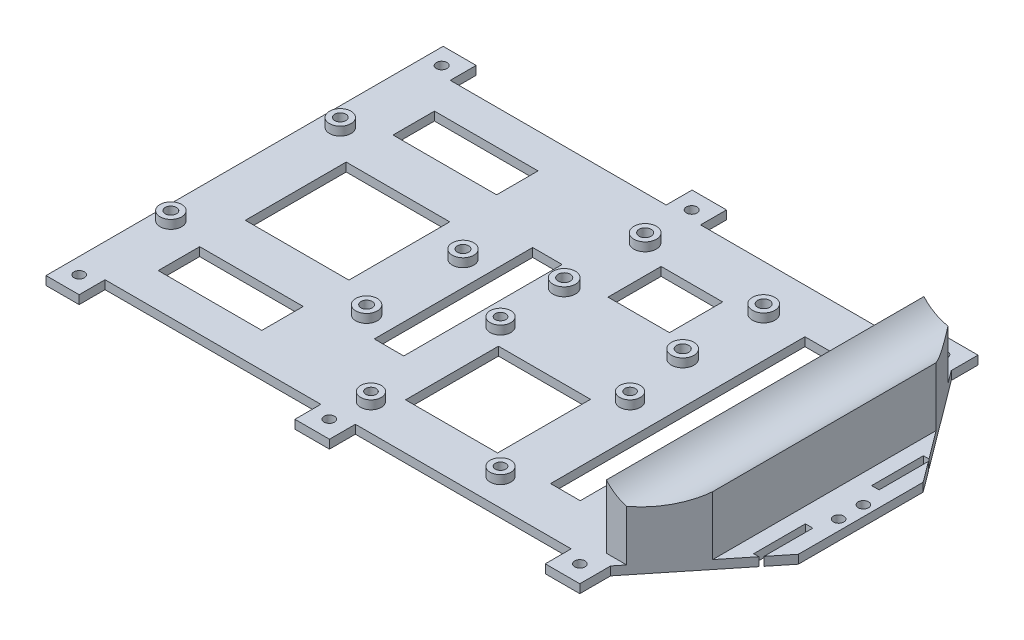
from build123d import *

# Parameters (mm, degrees)
BOSS_EXTRUDE1_DEPTH      = 2.5
SKETCH1_R                = 3.11925
SKETCH1_R_2              = 1.61925
BOSS_EXTRUDE2_DEPTH      = 2.5
SKETCH12_R               = 1.61925
CUT_EXTRUDE2_DEPTH       = 3.5
SKETCH15_R               = 3
BOSS_EXTRUDE6_DEPTH      = 2.5
SKETCH13_R               = 1.5
CUT_EXTRUDE5_DEPTH       = 3.5
CUT_EXTRUDE5_DEPTH_BACK  = 3.5
SKETCH16_R               = 3.25
SKETCH16_R_2             = 3.255054338
BOSS_EXTRUDE7_DEPTH      = 2.5
SKETCH17_R               = 1.75
SKETCH17_R_2             = 1.755054338
CUT_EXTRUDE6_DEPTH       = 1
CUT_EXTRUDE6_DEPTH_BACK  = 6
SKETCH24_R               = 1.534588162
SKETCH24_R_2             = 1.539679215
SKETCH24_R_3             = 1.53510928
SKETCH24_R_4             = 1.507254119
SKETCH24_R_5             = 1.501766116
SKETCH24_R_6             = 1.506723366
CUT_EXTRUDE7_DEPTH       = 3.5
CUT_EXTRUDE7_DEPTH_BACK  = 3.5
BOSS_EXTRUDE8_DEPTH      = 23
SKETCH28_W               = 1.910572049
SKETCH28_H               = 15
SKETCH28_W_2             = 2.161085764
CUT_EXTRUDE9_DEPTH       = 3.5
SKETCH30_W               = 30
SKETCH30_H               = 12
SKETCH30_W_2             = 8.543214141
SKETCH30_H_2             = 45.874985667
SKETCH30_H_3             = 29.216310988
SKETCH30_W_3             = 26.664834195
SKETCH30_H_4             = 26.922465443
SKETCH30_W_4             = 17.818641616
SKETCH30_H_5             = 15.402052611
SKETCH30_W_5             = 8.591934673
SKETCH30_H_6             = 73.671406809
CUT_EXTRUDE11_DEPTH      = 3.5
SKETCH29_R               = 12.3
CUT_EXTRUDE12_DEPTH      = 66.426944419
CUT_EXTRUDE12_DEPTH_BACK = 50.584496916
SKETCH31_R               = 1.5
CUT_EXTRUDE13_DEPTH      = 19.369261936
CUT_EXTRUDE13_DEPTH_BACK = 3.5
CUT_EXTRUDE14_DEPTH      = 12


with BuildPart() as part:
    # Sketch2 → Boss-Extrude1 (new body)
    with BuildSketch(Plane(origin=(0, -17.332299444, 0), x_dir=(-1, 0, 0), z_dir=(0, -1, 0))):
        Polygon((125.241603418, -58.531029956), (125.241603418, 41.468970044), (125.241603418, 48.975336237), (115.668802349, 48.975336237), (115.668802349, 41.468970044), (53.135946408, 41.468970044), (53.135946408, 48.975336237), (43.168799778, 48.975336237), (43.168799778, 41.468970044), (-19.254443916, 41.468970044), (-19.254443916, 48.975336237), (-29.674557938, 48.975336237), (-29.674557938, 41.234228149), (-53.610322333, 9.147791006), (-53.610322333, -26.975248892), (-29.352965282, -57.102703243), (-29.352965282, -66.036105098), (-19.352967368, -66.036105098), (-19.352967368, -58.531029956), (43.147035426, -58.531029956), (43.147035426, -66.036105098), (53.147035202, -66.036105098), (53.147035202, -58.531029956), (115.647037996, -58.531029956), (115.647037996, -66.036105098), (125.241603418, -66.036105098), align=None)
    extrude(amount=-BOSS_EXTRUDE1_DEPTH)

    # Sketch1 → Boss-Extrude2 (add)
    with BuildSketch(Plane(origin=(-134.962394185, -12.332299444, 36.871029956), x_dir=(1, 0, 0), z_dir=(0, 1, 0))):
        with Locations((14.01445, 2.71145)):
            Circle(SKETCH1_R)
        with Locations((14.01445, 2.71145)):
            Circle(SKETCH1_R_2, mode=Mode.SUBTRACT)
        with Locations((65.94475, 7.46125)):
            Circle(SKETCH1_R)
        with Locations((65.94475, 7.46125)):
            Circle(SKETCH1_R_2, mode=Mode.SUBTRACT)
        with Locations((65.94475, 35.38855)):
            Circle(SKETCH1_R)
        with Locations((65.94475, 35.38855)):
            Circle(SKETCH1_R_2, mode=Mode.SUBTRACT)
        with Locations((15.15745, 50.62855)):
            Circle(SKETCH1_R)
        with Locations((15.15745, 50.62855)):
            Circle(SKETCH1_R_2, mode=Mode.SUBTRACT)
    extrude(amount=-BOSS_EXTRUDE2_DEPTH)

    # Sketch12 → Cut-Extrude2 (cut, through all)
    with BuildSketch(Plane(origin=(0, -14.832299444, 0), x_dir=(1, 0, 0), z_dir=(0, 1, 0))):
        with Locations((-119.804944185, 13.757520044)):
            Circle(SKETCH12_R)
        with Locations((-69.017644185, -1.482479956)):
            Circle(SKETCH12_R)
        with Locations((-69.017644185, -29.409779956)):
            Circle(SKETCH12_R)
        with Locations((-120.947944185, -34.159579956)):
            Circle(SKETCH12_R)
    extrude(amount=-CUT_EXTRUDE2_DEPTH, mode=Mode.SUBTRACT)

    # Sketch15 → Boss-Extrude6 (add)
    with BuildSketch(Plane(origin=(0, -14.832299444, 0), x_dir=(1, 0, 0), z_dir=(0, 1, 0))):
        with Locations((-46.620694306, -50.539968272)):
            Circle(SKETCH15_R)
        with Locations((-46.620694306, -13.022091641)):
            Circle(SKETCH15_R)
        with Locations((-9.102817675, -50.539968272)):
            Circle(SKETCH15_R)
        with Locations((-9.102817675, -13.022091641)):
            Circle(SKETCH15_R)
    extrude(amount=BOSS_EXTRUDE6_DEPTH)

    # Sketch13 → Cut-Extrude5 (cut, two sides)
    with BuildSketch(Plane(origin=(0, -14.832299444, 0), x_dir=(1, 0, 0), z_dir=(0, 1, 0))) as cut_extrude5_sk:
        with Locations((-46.620694306, -13.022091641)):
            Circle(SKETCH13_R)
        with Locations((-9.102817675, -13.022091641)):
            Circle(SKETCH13_R)
        with Locations((-46.620694306, -50.539968272)):
            Circle(SKETCH13_R)
        with Locations((-9.102817675, -50.539968272)):
            Circle(SKETCH13_R)
    extrude(amount=CUT_EXTRUDE5_DEPTH, mode=Mode.SUBTRACT)
    extrude(cut_extrude5_sk.sketch, amount=-CUT_EXTRUDE5_DEPTH_BACK, mode=Mode.SUBTRACT)

    # Sketch16 → Boss-Extrude7 (add)
    with BuildSketch(Plane(origin=(0, -14.832299444, 0), x_dir=(1, 0, 0), z_dir=(0, 1, 0))):
        with Locations((-11.732899179, 28.299312351)):
            Circle(SKETCH16_R)
        with Locations((-12.172959949, 5.303522595)):
            Circle(SKETCH16_R_2)
        with Locations((-47.166553056, 5.973180288)):
            Circle(SKETCH16_R_2)
        with Locations((-46.726492287, 28.968970044)):
            Circle(SKETCH16_R)
    extrude(amount=BOSS_EXTRUDE7_DEPTH)

    # Sketch17 → Cut-Extrude6 (cut, two sides)
    with BuildSketch(Plane(origin=(0, -12.332299444, 0), x_dir=(1, 0, 0), z_dir=(0, 1, 0))) as cut_extrude6_sk:
        with Locations((-46.726492287, 28.968970044)):
            Circle(SKETCH17_R)
        with Locations((-47.166553056, 5.973180288)):
            Circle(SKETCH17_R_2)
        with Locations((-12.172959949, 5.303522595)):
            Circle(SKETCH17_R_2)
        with Locations((-11.732899179, 28.299312351)):
            Circle(SKETCH17_R)
    extrude(amount=CUT_EXTRUDE6_DEPTH, mode=Mode.SUBTRACT)
    extrude(cut_extrude6_sk.sketch, amount=-CUT_EXTRUDE6_DEPTH_BACK, mode=Mode.SUBTRACT)

    # Sketch24 → Cut-Extrude7 (cut, two sides)
    with BuildSketch(Plane(origin=(0, -14.832299444, 0), x_dir=(1, 0, 0), z_dir=(0, 1, 0))) as cut_extrude7_sk:
        with Locations((-120.631514326, 43.936289371)):
            Circle(SKETCH24_R)
        with Locations((-48.193182725, 43.936289371)):
            Circle(SKETCH24_R_2)
        with Locations((24.374871647, 43.936289371)):
            Circle(SKETCH24_R_3)
        with Locations((24.374871647, -61.035755979)):
            Circle(SKETCH24_R_4)
        with Locations((-48.193182725, -61.035755979)):
            Circle(SKETCH24_R_5)
        with Locations((-120.631514326, -61.035755979)):
            Circle(SKETCH24_R_6)
    extrude(amount=CUT_EXTRUDE7_DEPTH, mode=Mode.SUBTRACT)
    extrude(cut_extrude7_sk.sketch, amount=-CUT_EXTRUDE7_DEPTH_BACK, mode=Mode.SUBTRACT)

    # Sketch25 → Boss-Extrude8 (add)
    with BuildSketch(Plane(origin=(0, -14.832299444, 0), x_dir=(1, 0, 0), z_dir=(0, 1, 0))):
        Polygon((25.524416428, 37.468970044), (32.483356263, 37.468970044), (42.544257405, 23.982102995), (42.544257405, -40.719218001), (31.423568275, -54.531029956), (25.524416428, -54.531029956), align=None)
    extrude(amount=BOSS_EXTRUDE8_DEPTH)

    # Sketch28 → Cut-Extrude9 (cut, through all)
    with BuildSketch(Plane(origin=(0, -14.832299444, 0), x_dir=(1, 0, 0), z_dir=(0, 1, 0))):
        with Locations((21.640674678, -25.829400353)):
            Rectangle(SKETCH28_W, SKETCH28_H)
        with Locations((21.640674678, 8.33851306)):
            Rectangle(SKETCH28_W, SKETCH28_H)
        with Locations((48.076503584, -25.829400353)):
            Rectangle(SKETCH28_W_2, SKETCH28_H)
        with Locations((48.076503584, 8.33851306)):
            Rectangle(SKETCH28_W_2, SKETCH28_H)
    extrude(amount=-CUT_EXTRUDE9_DEPTH, mode=Mode.SUBTRACT)

    # Sketch30 → Cut-Extrude11 (cut, through all)
    with BuildSketch(Plane(origin=(0, -14.832299444, 0), x_dir=(1, 0, 0), z_dir=(0, 1, 0))):
        with Locations((-95.241603418, -42.531029956)):
            Rectangle(SKETCH30_W, SKETCH30_H)
        with Locations((-95.241603418, 25.468970044)):
            Rectangle(SKETCH30_W, SKETCH30_H)
        with Locations((-57.539223691, -11.460765675)):
            Rectangle(SKETCH30_W_2, SKETCH30_H_2)
        with Locations((-95.241603418, -8.701691218)):
            Rectangle(SKETCH30_W, SKETCH30_H_3)
        with Locations((-28.677773335, -31.68039269)):
            Rectangle(SKETCH30_W_3, SKETCH30_H_4)
        with Locations((-29.547493126, 17.632663699)):
            Rectangle(SKETCH30_W_4, SKETCH30_H_5)
        with Locations((4.295967337, -8.305922008)):
            Rectangle(SKETCH30_W_5, SKETCH30_H_6)
    extrude(amount=-CUT_EXTRUDE11_DEPTH, mode=Mode.SUBTRACT)

    # Sketch29 → Cut-Extrude12 (cut, two sides)
    with BuildSketch(Plane(origin=(0, 0, 16.451608182), x_dir=(-1, 0, 0), z_dir=(0, 0, -1))) as cut_extrude12_sk:
        with Locations((-34.72344809, 11.701998712)):
            Circle(SKETCH29_R)
    extrude(amount=CUT_EXTRUDE12_DEPTH, mode=Mode.SUBTRACT)
    extrude(cut_extrude12_sk.sketch, amount=-CUT_EXTRUDE12_DEPTH_BACK, mode=Mode.SUBTRACT)

    # Sketch31 → Cut-Extrude13 (cut, two sides)
    with BuildSketch(Plane(origin=(0, -14.832299444, 0), x_dir=(1, 0, 0), z_dir=(0, 1, 0))) as cut_extrude13_sk:
        with Locations((50.610322333, -12.329400353)):
            Circle(SKETCH31_R)
        with Locations((50.610322333, -5.16148694)):
            Circle(SKETCH31_R)
    extrude(amount=CUT_EXTRUDE13_DEPTH, mode=Mode.SUBTRACT)
    extrude(cut_extrude13_sk.sketch, amount=-CUT_EXTRUDE13_DEPTH_BACK, mode=Mode.SUBTRACT)

    # Sketch32 → Cut-Extrude14 (cut)
    with BuildSketch(Plane.XZ.offset(17.332299444)):
        Polygon((30.524416428, 47.675089459), (30.524416428, -31.732854607), (37.544257405, -22.322597948), (37.544257405, 38.956499954), align=None)
    extrude(amount=-CUT_EXTRUDE14_DEPTH, mode=Mode.SUBTRACT)


solid = part.part
